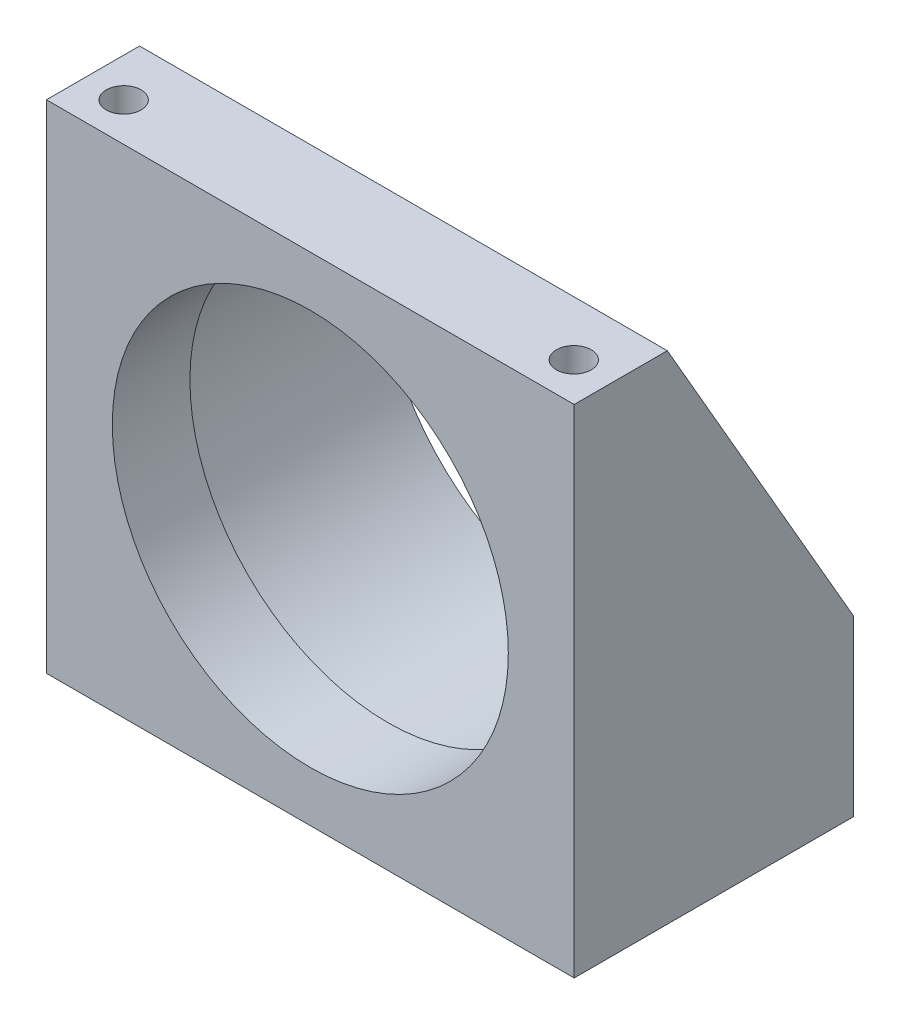
from build123d import *

# Parameters (mm, degrees)
SKETCH1_W          = 107.95
SKETCH1_H          = 101.6
SKETCH1_R          = 40.5003
EXTRUDE1_DEPTH     = 57.15
CUT_EXTRUDE1_DEPTH = 108.95
SKETCH3_R          = 42.926
CUT_EXTRUDE2_DEPTH = 41.275
FILLET1_R          = 1.524
HOLE1_D            = 7.1374
HOLE1_DEPTH        = 101.6


with BuildPart() as part:
    # Sketch1 → Extrude1 (new body)
    with BuildSketch(Plane.XY):
        with Locations((0, 50.8)):
            Rectangle(SKETCH1_W, SKETCH1_H)
        with Locations((0, 50.8)):
            Circle(SKETCH1_R, mode=Mode.SUBTRACT)
    extrude(amount=-EXTRUDE1_DEPTH)

    # Sketch2 → Cut-Extrude1 (cut, through all)
    with BuildSketch(Plane(origin=(53.975, 0, 0), x_dir=(0, 0, -1), z_dir=(1, 0, 0))):
        Polygon((19.05, 101.6), (57.15, 35.56), (57.15, 101.6), align=None)
    extrude(amount=-CUT_EXTRUDE1_DEPTH, mode=Mode.SUBTRACT)

    # Sketch3 → Cut-Extrude2 (cut)
    with BuildSketch(Plane(origin=(0, 0, -57.15), x_dir=(-1, 0, 0), z_dir=(0, 0, -1))):
        with Locations(Location((0, 50.8, 0), (0, 0, 339.204742364))):  # turned: the seam where the file's is
            Circle(SKETCH3_R)
    extrude(amount=-CUT_EXTRUDE2_DEPTH, mode=Mode.SUBTRACT)

    # Fillet1
    fillet1_edges = [part.edges().sort_by_distance(p)[0] for p in [
        (40.129588535, 66.04, -15.875),
    ]]
    fillet(fillet1_edges, radius=FILLET1_R)

    # Hole1
    with Locations(Plane(origin=(0, 101.6, 0), x_dir=(-1, 0, 0), z_dir=(0, 1, 0))):
        with Locations((46.0502, -7.874), (-46.0248, -7.874)):
            Hole(HOLE1_D / 2, depth=HOLE1_DEPTH)


solid = part.part
